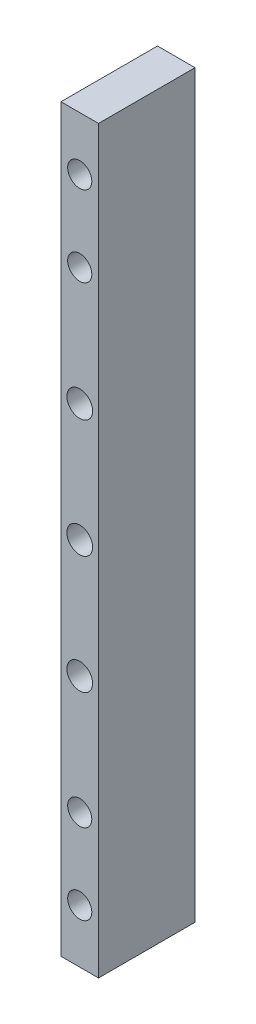
from build123d import *

# Parameters (mm, degrees)
SKETCH_1_W         = 7
SKETCH_1_H         = 138
EXTRUDE_1_DEPTH    = 18
HOLE_WIZARD_M4_1_D = 4.8
HOLE_WIZARD_M4_2_D = 4.5


with BuildPart() as part:
    # ｽｹｯﾁ1 → ﾎﾞｽ - 押し出し1 (new body)
    with BuildSketch(Plane.XY):
        Rectangle(SKETCH_1_W, SKETCH_1_H)
    extrude(amount=EXTRUDE_1_DEPTH)

    # M4 すきま穴1 (through all)
    with Locations(Plane.XY.offset(18)):
        with Locations((0, 0), (0, 22), (0, -22)):
            Hole(HOLE_WIZARD_M4_1_D / 2)

    # M4 すきま穴2 (through all)
    with Locations(Plane(origin=(0, 44, 18), x_dir=(1, 0, 0), z_dir=(0, 0, 1))):
        with Locations((0, 0), (0, 15)):
            hole_wizard_m4_2 = Hole(HOLE_WIZARD_M4_2_D / 2)

    # ﾐﾗｰ1: M4 すきま穴2 across plane
    add(hole_wizard_m4_2.mirror(Plane.ZX), mode=Mode.SUBTRACT)


solid = part.part
